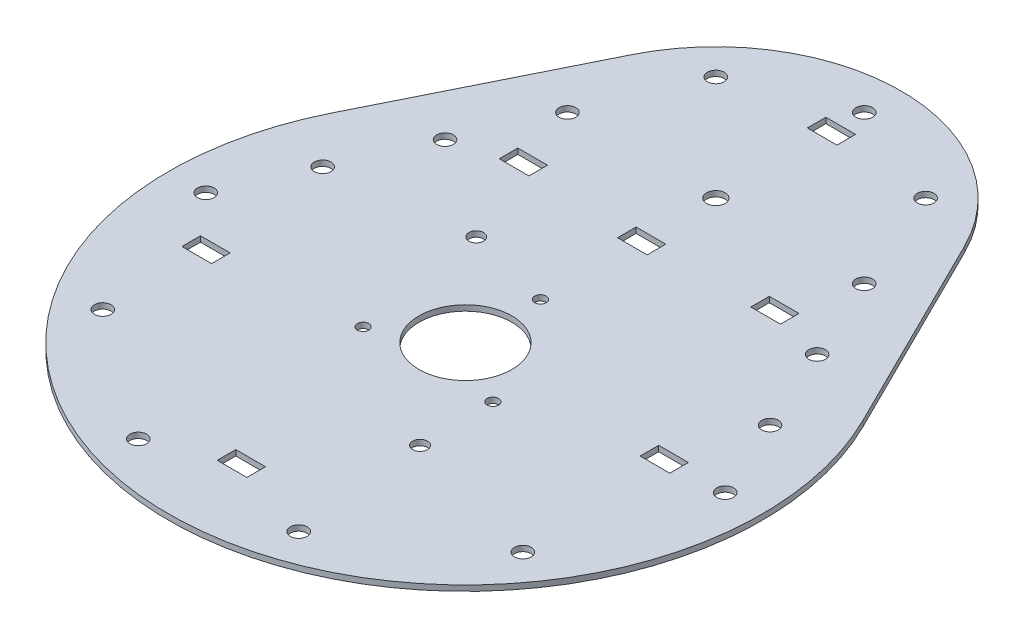
from build123d import *

# Parameters (mm, degrees)
SKETCH1_R           = 12.525
SKETCH1_R_2         = 1.55
SKETCH1_R_3         = 2.5
SKETCH1_R_4         = 2.25
SKETCH1_R_5         = 2
SKETCH1_W           = 8
SKETCH1_H           = 5
BOSS_EXTRUDE1_DEPTH = 1.5


with BuildPart() as part:
    # Sketch1 → Boss-Extrude1 (new body)
    with BuildSketch(Plane(origin=(0, 0, 0), x_dir=(1, 0, 0), z_dir=(0, 1, 0))):
        with BuildLine():
            Line((44.790320824, 89.722222222), (71.664513318, 35.555555556))
            ThreePointArc((71.664513318, 35.555555556), (0, -80), (-71.664513318, 35.555555556))
            Line((-71.664513318, 35.555555556), (-44.790320824, 89.722222222))
            ThreePointArc((-44.790320824, 89.722222222), (0, 117.5), (44.790320824, 89.722222222))
        make_face()
        Circle(SKETCH1_R, mode=Mode.SUBTRACT)
        with Locations((-17.5, -10.103629711)):
            Circle(SKETCH1_R_2, mode=Mode.SUBTRACT)
        with Locations((17.5, -10.103629711)):
            Circle(SKETCH1_R_2, mode=Mode.SUBTRACT)
        with Locations((0, 20.207259422)):
            Circle(SKETCH1_R_2, mode=Mode.SUBTRACT)
        with Locations((0, 67.5)):
            Circle(SKETCH1_R_3, mode=Mode.SUBTRACT)
        with Locations((40, 67.5)):
            Circle(SKETCH1_R_4, mode=Mode.SUBTRACT)
        with Locations((70, 0)):
            Circle(SKETCH1_R_4, mode=Mode.SUBTRACT)
        with Locations((56.631189606, -41.14496766)):
            Circle(SKETCH1_R_4, mode=Mode.SUBTRACT)
        with Locations((21.631189606, -66.573956141)):
            Circle(SKETCH1_R_4, mode=Mode.SUBTRACT)
        with Locations((-21.631189606, -66.573956141)):
            Circle(SKETCH1_R_4, mode=Mode.SUBTRACT)
        with Locations((-56.631189606, -41.14496766)):
            Circle(SKETCH1_R_4, mode=Mode.SUBTRACT)
        with Locations((-70, 0)):
            Circle(SKETCH1_R_4, mode=Mode.SUBTRACT)
        with Locations((28.284271247, 95.784271247)):
            Circle(SKETCH1_R_4, mode=Mode.SUBTRACT)
        with Locations((0, 107.5)):
            Circle(SKETCH1_R_4, mode=Mode.SUBTRACT)
        with Locations((-28.284271247, 95.784271247)):
            Circle(SKETCH1_R_4, mode=Mode.SUBTRACT)
        with Locations((-40, 67.5)):
            Circle(SKETCH1_R_4, mode=Mode.SUBTRACT)
        with Locations((-50.153461651, 44.654711284)):
            Circle(SKETCH1_R_4, mode=Mode.SUBTRACT)
        with Locations((-60.306923303, 21.809422569)):
            Circle(SKETCH1_R_4, mode=Mode.SUBTRACT)
        with Locations((50.153461651, 44.654711284)):
            Circle(SKETCH1_R_4, mode=Mode.SUBTRACT)
        with Locations((60.306923303, 21.809422569)):
            Circle(SKETCH1_R_4, mode=Mode.SUBTRACT)
        with Locations((17.859623375, -30.100396225)):
            Circle(SKETCH1_R_5, mode=Mode.SUBTRACT)
        with Locations((-23.249483938, 26.162215055)):
            Circle(SKETCH1_R_5, mode=Mode.SUBTRACT)
        with Locations((0, 47.5)):
            Rectangle(SKETCH1_W, SKETCH1_H, mode=Mode.SUBTRACT)
        with Locations((-1.994503305, -58.420364393)):
            Rectangle(SKETCH1_W, SKETCH1_H, mode=Mode.SUBTRACT)
        with Locations((-34.37581539, 50)):
            Rectangle(SKETCH1_W, SKETCH1_H, mode=Mode.SUBTRACT)
        with Locations((34.136464886, 49.290075758)):
            Rectangle(SKETCH1_W, SKETCH1_H, mode=Mode.SUBTRACT)
        with Locations((54.012994775, -0.420504721)):
            Rectangle(SKETCH1_W, SKETCH1_H, mode=Mode.SUBTRACT)
        with Locations((-56.673760324, -13.260168312)):
            Rectangle(SKETCH1_W, SKETCH1_H, mode=Mode.SUBTRACT)
        with Locations((-0.046638908, 98.711772009)):
            Rectangle(SKETCH1_W, SKETCH1_H, mode=Mode.SUBTRACT)
    extrude(amount=BOSS_EXTRUDE1_DEPTH)


solid = part.part
